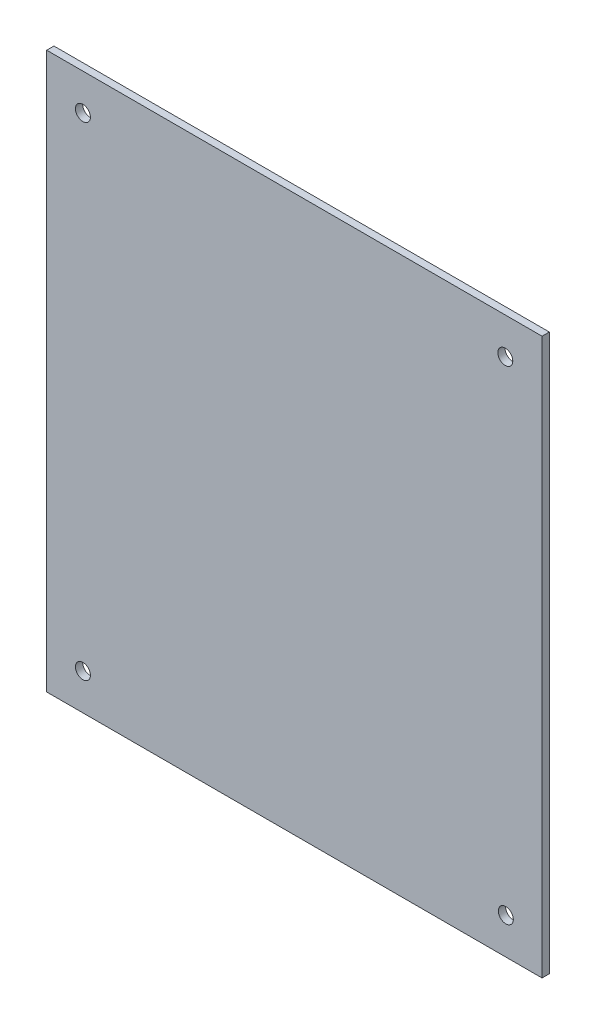
from build123d import *

# Parameters (mm, degrees)
CROQUIS1_W              = 205
CROQUIS1_H              = 230
CROQUIS1_R              = 3.1
SALIENTE_EXTRUIR1_DEPTH = 3


with BuildPart() as part:
    # Croquis1 → Saliente-Extruir1 (new body)
    with BuildSketch(Plane.XY):
        Rectangle(CROQUIS1_W, CROQUIS1_H)
        with Locations((-87.5, 100)):
            Circle(CROQUIS1_R, mode=Mode.SUBTRACT)
        with Locations((87.275174875, 100)):
            Circle(CROQUIS1_R, mode=Mode.SUBTRACT)
        with Locations((-87.5, -100)):
            Circle(CROQUIS1_R, mode=Mode.SUBTRACT)
        with Locations((87.5, -100)):
            Circle(CROQUIS1_R, mode=Mode.SUBTRACT)
    extrude(amount=SALIENTE_EXTRUIR1_DEPTH)


solid = part.part
